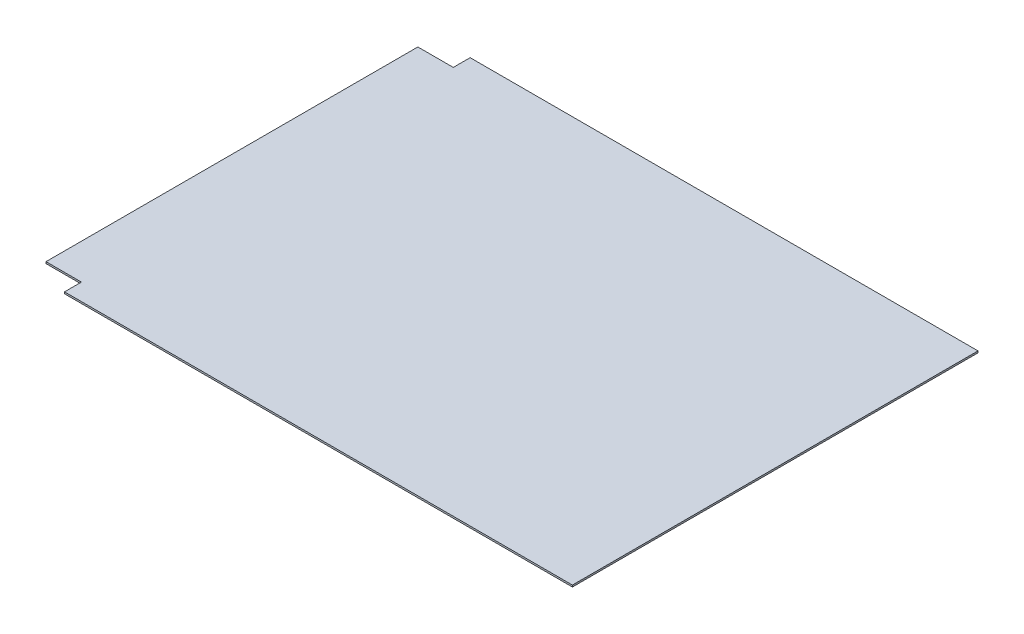
from build123d import *

# Parameters (mm, degrees)
BOSS_EXTRUDE1_DEPTH = 1.31064


with BuildPart() as part:
    # Sketch1 → Boss-Extrude1 (new body)
    with BuildSketch(Plane(origin=(0, 0, 0), x_dir=(1, 0, 0), z_dir=(0, 1, 0))):
        Polygon((-382.408, 0), (-382.408, 12.7), (-409.078, 12.7), (-409.078, 292.7), (-382.408, 292.7), (-382.408, 305.4), (0, 305.4), (0, 0), align=None)
    extrude(amount=BOSS_EXTRUDE1_DEPTH)


solid = part.part
